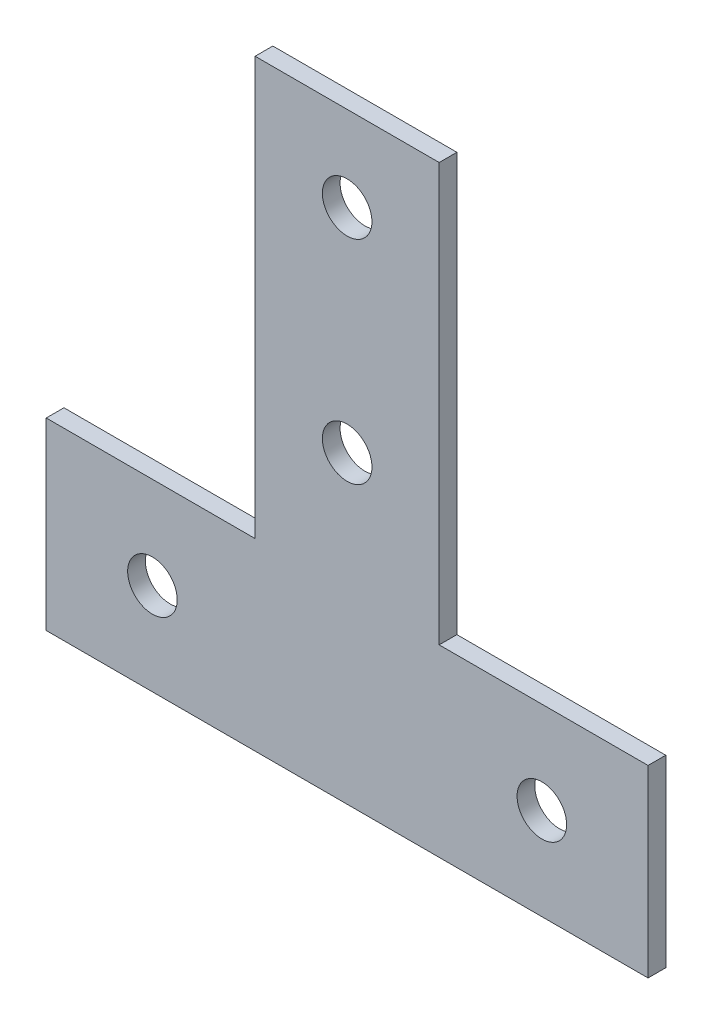
from build123d import *

# Parameters (mm, degrees)
SKETCH_1_R      = 3.5
EXTRUDE_1_DEPTH = 2.5


with BuildPart() as part:
    # Эскиз1 → Бобышка-Вытянуть1 (new body)
    with BuildSketch(Plane.XY):
        Polygon((-42.5, 0), (42.5, 0), (42.5, 26), (13, 26), (13, 85), (-13, 85), (-13, 26), (-42.5, 26), align=None)
        with Locations((0, 73)):
            Circle(SKETCH_1_R, mode=Mode.SUBTRACT)
        with Locations((0, 43)):
            Circle(SKETCH_1_R, mode=Mode.SUBTRACT)
        with Locations((-27.5, 13)):
            Circle(SKETCH_1_R, mode=Mode.SUBTRACT)
        with Locations((27.5, 13)):
            Circle(SKETCH_1_R, mode=Mode.SUBTRACT)
    extrude(amount=EXTRUDE_1_DEPTH)


solid = part.part
